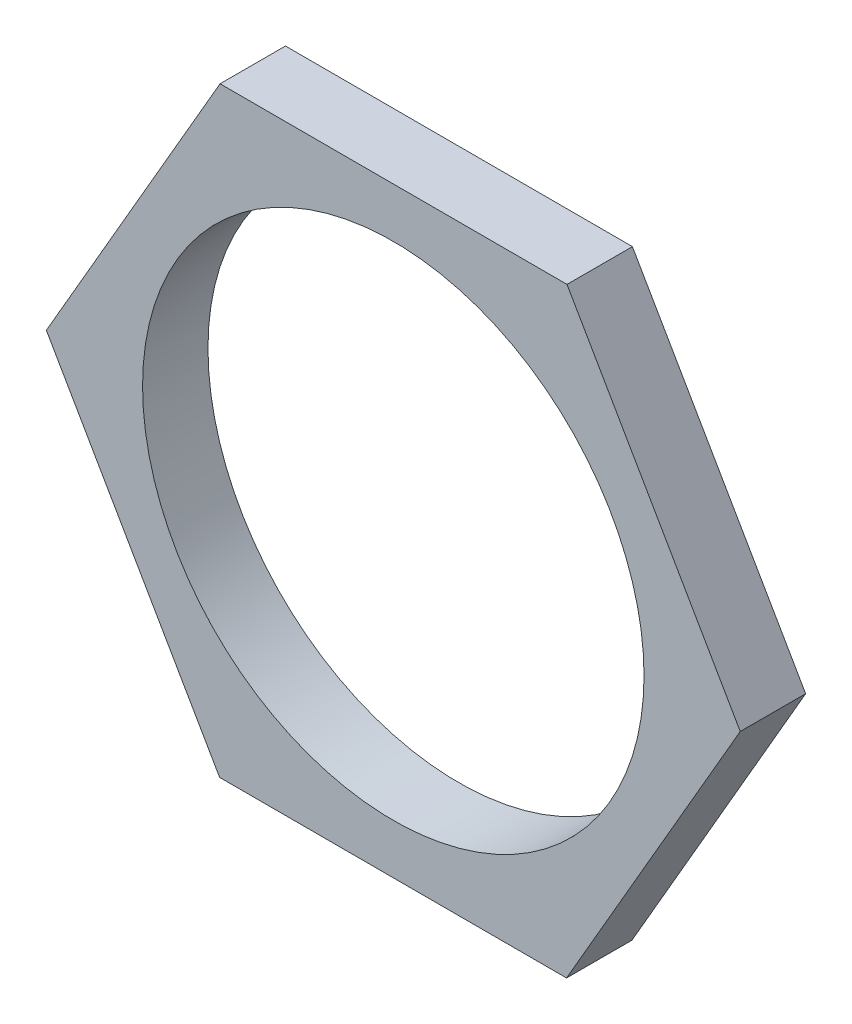
from build123d import *

# Parameters (mm, degrees)
CROQUIS1_R              = 11.5
SALIENTE_EXTRUIR1_DEPTH = 3


with BuildPart() as part:
    # Croquis1 → Saliente-Extruir1 (new body)
    with BuildSketch(Plane.XY):
        Polygon((7.966989997, 13.774204899), (-7.94531636, 13.786718179), (-15.912306358, 0.01251328), (-7.966989997, -13.774204899), (7.94531636, -13.786718179), (15.912306358, -0.01251328), align=None)
        Circle(CROQUIS1_R, mode=Mode.SUBTRACT)
    extrude(amount=SALIENTE_EXTRUIR1_DEPTH)


solid = part.part
